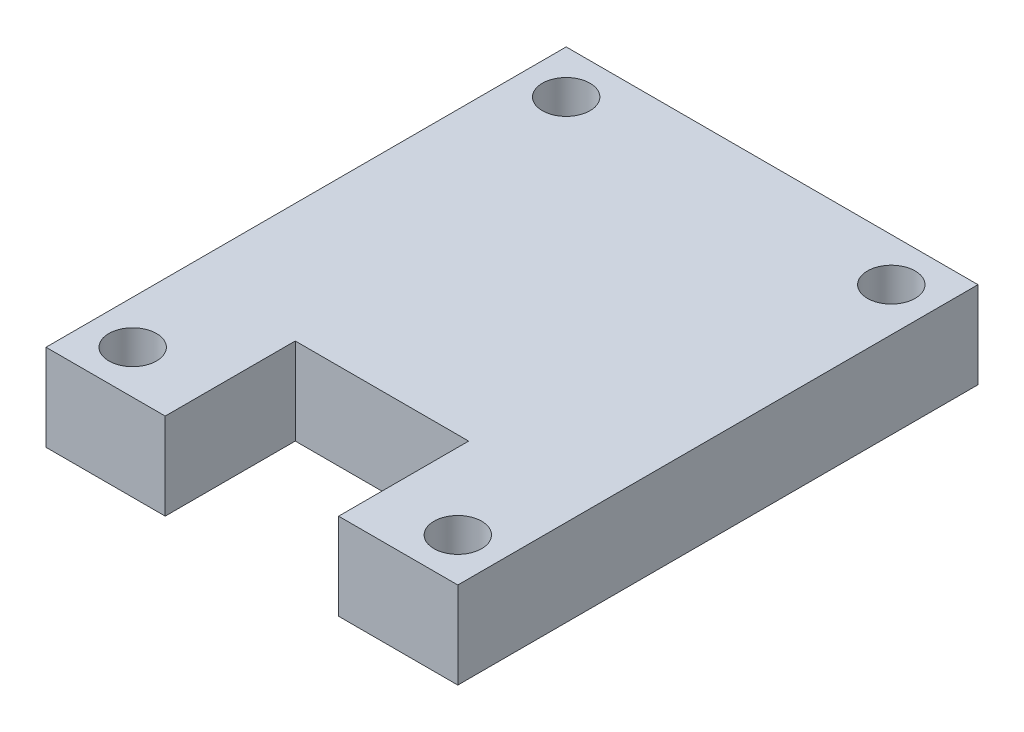
from build123d import *

# Parameters (mm, degrees)
ESQUISSE1_W             = 38
ESQUISSE1_H             = 48
BOSS_EXTRU_1_DEPTH      = 8
ESQUISSE3_R             = 2.2
ENL_V_MAT_EXTRU_1_DEPTH = 8
ENL_V_MAT_EXTRU_2_DEPTH = 8


with BuildPart() as part:
    # Esquisse1 → Boss.-Extru.1 (new body)
    with BuildSketch(Plane(origin=(0, 0, 0), x_dir=(1, 0, 0), z_dir=(0, 1, 0))):
        with Locations((19, 24)):
            Rectangle(ESQUISSE1_W, ESQUISSE1_H)
    extrude(amount=BOSS_EXTRU_1_DEPTH)

    # Esquisse3 → Enlèv. mat.-Extru.1 (cut)
    with BuildSketch(Plane.XZ):
        with Locations((4, -4)):
            Circle(ESQUISSE3_R)
        with Locations((34, -4)):
            Circle(ESQUISSE3_R)
        with Locations((34, -44)):
            Circle(ESQUISSE3_R)
        with Locations((4, -44)):
            Circle(ESQUISSE3_R)
    extrude(amount=-ENL_V_MAT_EXTRU_1_DEPTH, mode=Mode.SUBTRACT)

    # Esquisse5 → Enlèv. mat.-Extru.2 (cut)
    with BuildSketch(Plane(origin=(0, 8, 0), x_dir=(1, 0, 0), z_dir=(0, 1, 0))):
        Polygon((19, 12), (27, 12), (27, 0), (11, 0), (11, 12), align=None)
    extrude(amount=-ENL_V_MAT_EXTRU_2_DEPTH, mode=Mode.SUBTRACT)


solid = part.part
